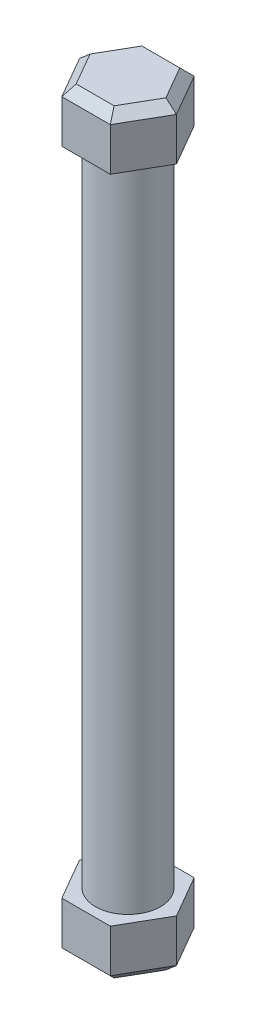
from build123d import *

# Parameters (mm, degrees)
SKETCH1_R           = 2.5
BOSS_EXTRUDE1_DEPTH = 50
BOSS_EXTRUDE2_DEPTH = 4
CHAMFER1_SIZE       = 0.7
BOSS_EXTRUDE3_DEPTH = 4
CHAMFER2_SIZE       = 0.7


with BuildPart() as part:
    # Sketch1 → Boss-Extrude1 (new body)
    with BuildSketch(Plane(origin=(0, 0, 0), x_dir=(1, 0, 0), z_dir=(0, 1, 0))):
        Circle(SKETCH1_R)
    extrude(amount=BOSS_EXTRUDE1_DEPTH)

    # Sketch2 → Boss-Extrude2 (add)
    with BuildSketch(Plane(origin=(0, 50, 0), x_dir=(1, 0, 0), z_dir=(0, 1, 0))):
        Polygon((3.720037117, 0), (1.860018559, 3.221646647), (-1.860018559, 3.221646647), (-3.720037117, 0), (-1.860018559, -3.221646647), (1.860018559, -3.221646647), align=None)
    extrude(amount=BOSS_EXTRUDE2_DEPTH)

    # Chamfer1
    chamfer1_edges = [part.edges().sort_by_distance(p)[0] for p in [
        (2.790027838, 54, 1.610823323),
        (2.790027838, 54, -1.610823323),
        (0, 54, -3.221646647),
        (-2.790027838, 54, -1.610823323),
        (-2.790027838, 54, 1.610823323),
        (0, 54, 3.221646647),
    ]]
    chamfer(chamfer1_edges, length=CHAMFER1_SIZE)

    # Sketch3 → Boss-Extrude3 (add)
    with BuildSketch(Plane.XZ):
        Polygon((3.720037117, 0), (1.860018559, 3.221646647), (-1.860018559, 3.221646647), (-3.720037117, 0), (-1.860018559, -3.221646647), (1.860018559, -3.221646647), align=None)
    extrude(amount=BOSS_EXTRUDE3_DEPTH)

    # Chamfer2
    chamfer2_edges = [part.edges().sort_by_distance(p)[0] for p in [
        (2.790027838, -4, -1.610823323),
        (2.790027838, -4, 1.610823323),
        (0, -4, 3.221646647),
        (-2.790027838, -4, 1.610823323),
        (-2.790027838, -4, -1.610823323),
        (0, -4, -3.221646647),
    ]]
    chamfer(chamfer2_edges, length=CHAMFER2_SIZE)


solid = part.part
